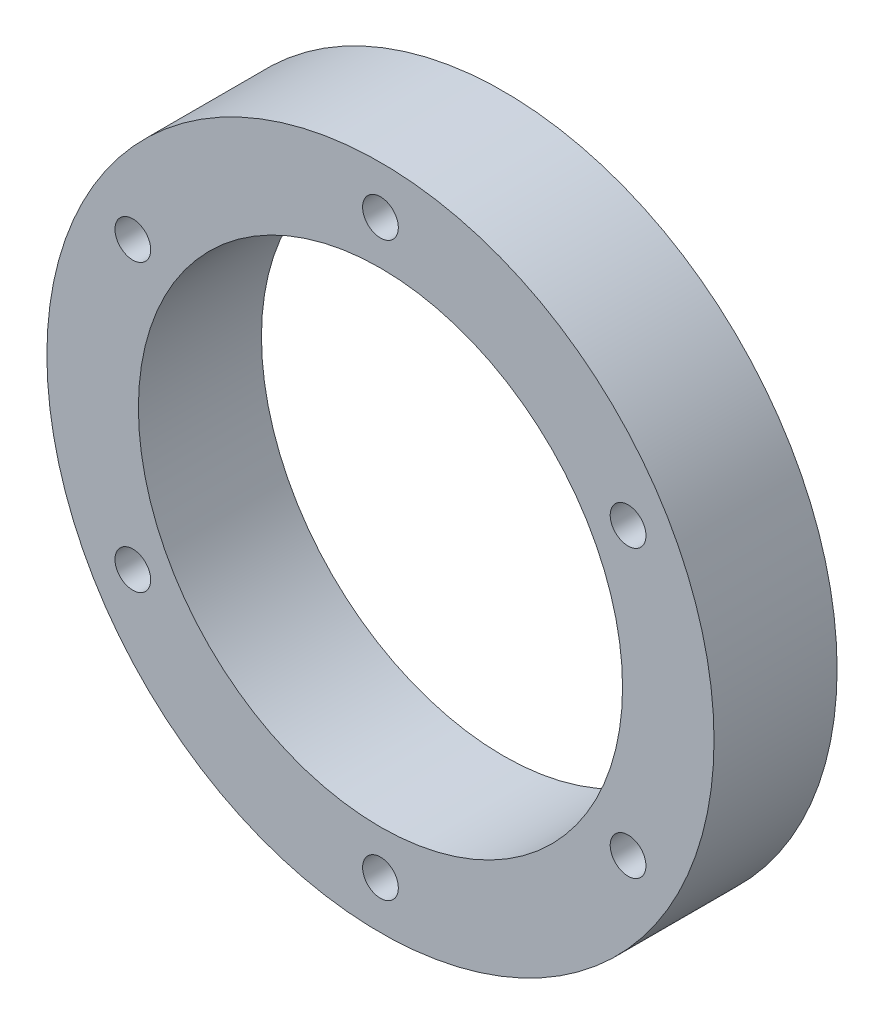
from build123d import *

# Parameters (mm, degrees)
SKETCH1_R           = 22.225
SKETCH1_R_2         = 16.129
BOSS_EXTRUDE1_DEPTH = 8.2
CIRPATTERN1_COUNT   = 6


with BuildPart() as part:
    # Sketch1 → Boss-Extrude1 (new body)
    with BuildSketch(Plane.XY):
        Circle(SKETCH1_R)
        Circle(SKETCH1_R_2, mode=Mode.SUBTRACT)
    extrude(amount=BOSS_EXTRUDE1_DEPTH)

    # Sketch2 → 3/32 (0.09375) Diameter Hole1 (revolve, cut)
    with BuildSketch(Plane(origin=(0, 19.05, 8.2), x_dir=(0, -1, 0), z_dir=(1, 0, 0))):
        Polygon((0, 0), (0, 26.115399675), (1.190625, 25.4), (1.190625, 0), align=None)
    f_3_32_0_09375_diameter_hole1 = revolve(axis=Axis((0, 19.05, 14.55), (0, 0, -1)), mode=Mode.SUBTRACT)

    # CirPattern1: 3/32 (0.09375) Diameter Hole1 ×6 about axis
    cirpattern1_axis = Axis((0, 0, 0), (0, 0, 1))
    for i in range(1, CIRPATTERN1_COUNT):
        add(f_3_32_0_09375_diameter_hole1.rotate(cirpattern1_axis, i * 360 / CIRPATTERN1_COUNT), mode=Mode.SUBTRACT)


solid = part.part
